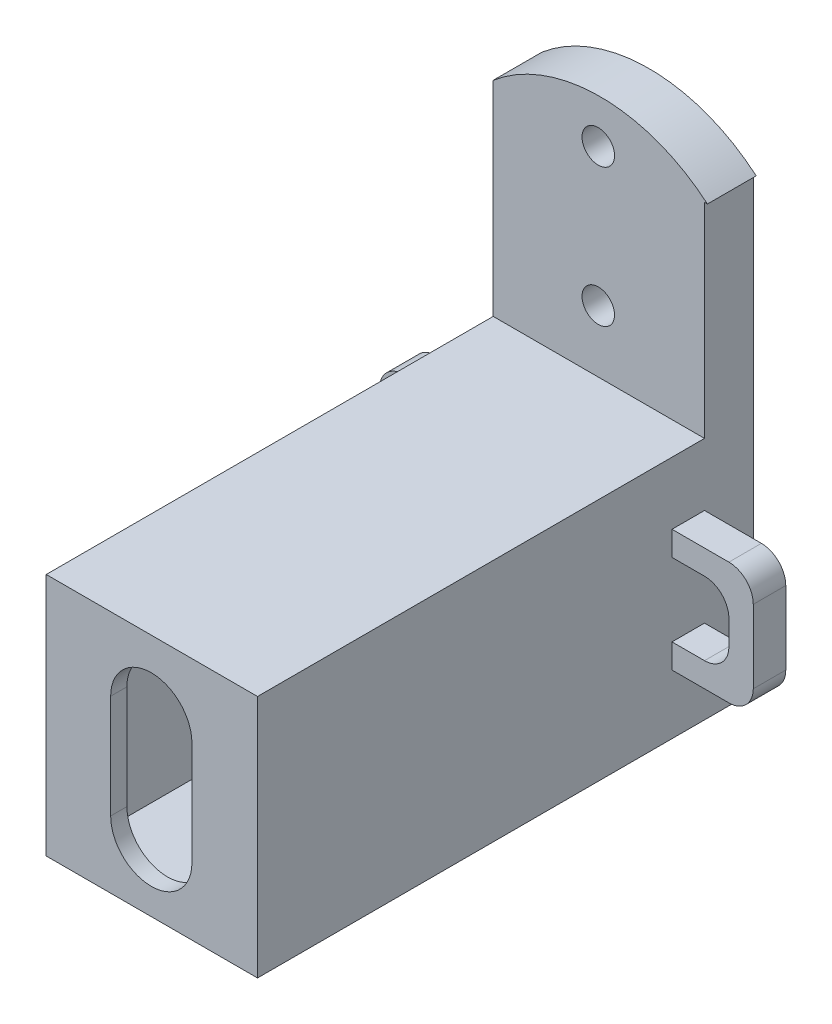
from build123d import *

# Parameters (mm, degrees)
BOSS_EXTRUDE1_DEPTH = 3
SKETCH2_W           = 13
SKETCH2_H           = 15
BOSS_EXTRUDE2_DEPTH = 27.5
SKETCH3_W           = 10.6
SKETCH3_H           = 13
CUT_EXTRUDE1_DEPTH  = 26.5
CUT_EXTRUDE2_DEPTH  = 31.5
SKETCH5_W           = 1.5
SKETCH5_H           = 27.57988307
CUT_EXTRUDE3_DEPTH  = 4
BOSS_EXTRUDE4_DEPTH = 2
FILLET2_R           = 1.5
FILLET3_R           = 1.5
SKETCH7_R           = 1
CUT_EXTRUDE4_DEPTH  = 4


with BuildPart() as part:
    # Sketch1 → Boss-Extrude1 (new body)
    with BuildSketch(Plane.XY):
        with BuildLine():
            Line((8.035256759, -13.057292233), (-7.964743241, -13.057292233))
            Line((-7.964743241, -13.057292233), (-7.964743241, 12.942707767))
            ThreePointArc((-7.964743241, 12.942707767), (-0.020633322, 16.942707767), (8.035256759, 13.172891138))
            Line((8.035256759, 13.172891138), (8.035256759, -13.057292233))
        make_face()
    extrude(amount=BOSS_EXTRUDE1_DEPTH)

    # Sketch2 → Boss-Extrude2 (add)
    with BuildSketch(Plane.XY.offset(3)):
        with Locations((0.035256759, -5.557292233)):
            Rectangle(SKETCH2_W, SKETCH2_H)
    extrude(amount=BOSS_EXTRUDE2_DEPTH)

    # Sketch3 → Cut-Extrude1 (cut, symmetric)
    with BuildSketch(Plane.XY.offset(3)):
        with Locations((-0.014743241, -5.807292233)):
            Rectangle(SKETCH3_W, SKETCH3_H)
    extrude(amount=CUT_EXTRUDE1_DEPTH, both=True, mode=Mode.SUBTRACT)

    # Sketch4 → Cut-Extrude2 (cut, through all)
    with BuildSketch(Plane.XY.offset(30.5)):
        with BuildLine():
            Line((-2.5, -8.94154935), (-2.5, -2.55973464))
            ThreePointArc((-2.5, -2.55973464), (0, -0.05973464), (2.5, -2.55973464))
            Line((2.5, -2.55973464), (2.5, -8.94154935))
            ThreePointArc((2.5, -8.94154935), (0, -11.44154935), (-2.5, -8.94154935))
        make_face()
    extrude(amount=-CUT_EXTRUDE2_DEPTH, mode=Mode.SUBTRACT)

    # Sketch5 → Cut-Extrude3 (cut, through all)
    with BuildSketch(Plane.XY.offset(3)):
        with Locations((-7.214743241, 0.732649302)):
            Rectangle(SKETCH5_W, SKETCH5_H)
        with Locations((7.285256759, 0.732649302)):
            Rectangle(SKETCH5_W, SKETCH5_H)
    extrude(amount=-CUT_EXTRUDE3_DEPTH, mode=Mode.SUBTRACT)

    # Sketch6 → Boss-Extrude4 (add)
    with BuildSketch(Plane.XY.offset(3)):
        Polygon((-6.464743241, -3.398686813), (-9.964743241, -3.398686813), (-9.964743241, -7.898686813), (-6.464743241, -7.898686813), (-6.464743241, -9.398686813), (-11.464743241, -9.398686813), (-11.464743241, -1.898686813), (-6.464743241, -1.898686813), align=None)
        Polygon((6.535256759, -3.398686813), (6.535256759, -1.898686813), (11.535256759, -1.898686813), (11.535256759, -9.398686813), (6.535256759, -9.398686813), (6.535256759, -7.898686813), (10.035256759, -7.898686813), (10.035256759, -3.398686813), align=None)
    extrude(amount=BOSS_EXTRUDE4_DEPTH)

    # Fillet2
    fillet2_edges = [part.edges().sort_by_distance(p)[0] for p in [
        (-9.964743241, -3.398686813, 4),
        (-11.464743241, -1.898686813, 4),
        (-11.464743241, -9.398686813, 4),
        (-9.964743241, -7.898686813, 4),
    ]]
    fillet(fillet2_edges, radius=FILLET2_R)

    # Fillet3
    fillet3_edges = [part.edges().sort_by_distance(p)[0] for p in [
        (10.035256759, -3.398686813, 4),
        (10.035256759, -7.898686813, 4),
        (11.535256759, -9.398686813, 4),
        (11.535256759, -1.898686813, 4),
    ]]
    fillet(fillet3_edges, radius=FILLET3_R)

    # Sketch7 → Cut-Extrude4 (cut, through all)
    with BuildSketch(Plane.XY.offset(3)):
        with Locations((0, 14.234326683)):
            Circle(SKETCH7_R)
        with Locations((0, 5.748094445)):
            Circle(SKETCH7_R)
    extrude(amount=-CUT_EXTRUDE4_DEPTH, mode=Mode.SUBTRACT)


solid = part.part
